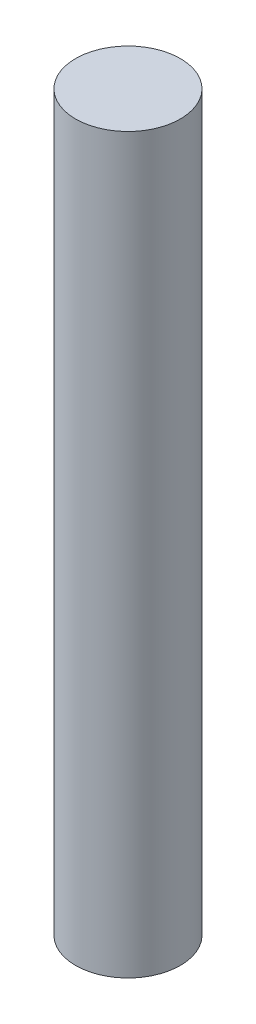
from build123d import *

# Parameters (mm, degrees)
SKETCH1_R           = 2.54
BOSS_EXTRUDE1_DEPTH = 35.56


with BuildPart() as part:
    # Sketch1 → Boss-Extrude1 (new body)
    with BuildSketch(Plane(origin=(0, 0, 0), x_dir=(1, 0, 0), z_dir=(0, 1, 0))):
        with Locations((-7.885947401, -0.297913568)):
            Circle(SKETCH1_R)
    extrude(amount=BOSS_EXTRUDE1_DEPTH)


solid = part.part
